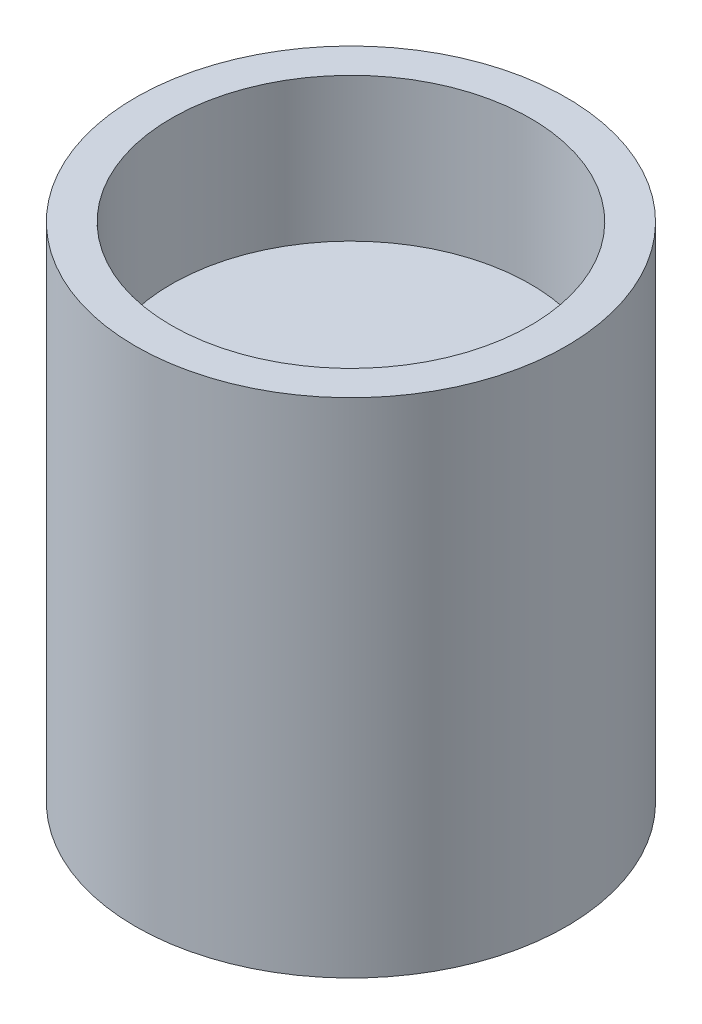
from build123d import *

# Parameters (mm, degrees)
SKETCH_1_R          = 3
EXTRUDE_1_DEPTH     = 7
CUT_EXTRUDE_1_DEPTH = 2.5
SKETCH_5_R          = 2.5
CUT_EXTRUDE_2_DEPTH = 2


with BuildPart() as part:
    # 草图1 → 凸台-拉伸1 (new body)
    with BuildSketch(Plane(origin=(0, 0, 0), x_dir=(1, 0, 0), z_dir=(0, 1, 0))):
        Circle(SKETCH_1_R)
    extrude(amount=EXTRUDE_1_DEPTH)

    # 草图4 → 切除-拉伸1 (cut)
    with BuildSketch(Plane(origin=(0, 0, 0), x_dir=(1, 0, 0), z_dir=(0, 1, 0))):
        with BuildLine():
            Line((0.829156198, -1.25), (0.829156198, 1.25))
            ThreePointArc((0.829156198, 1.25), (-1.5, 0), (0.829156198, -1.25))
        make_face()
    extrude(amount=CUT_EXTRUDE_1_DEPTH, mode=Mode.SUBTRACT)

    # 草图5 → 切除-拉伸2 (cut)
    with BuildSketch(Plane(origin=(0, 7, 0), x_dir=(1, 0, 0), z_dir=(0, 1, 0))):
        Circle(SKETCH_5_R)
    extrude(amount=-CUT_EXTRUDE_2_DEPTH, mode=Mode.SUBTRACT)


solid = part.part
